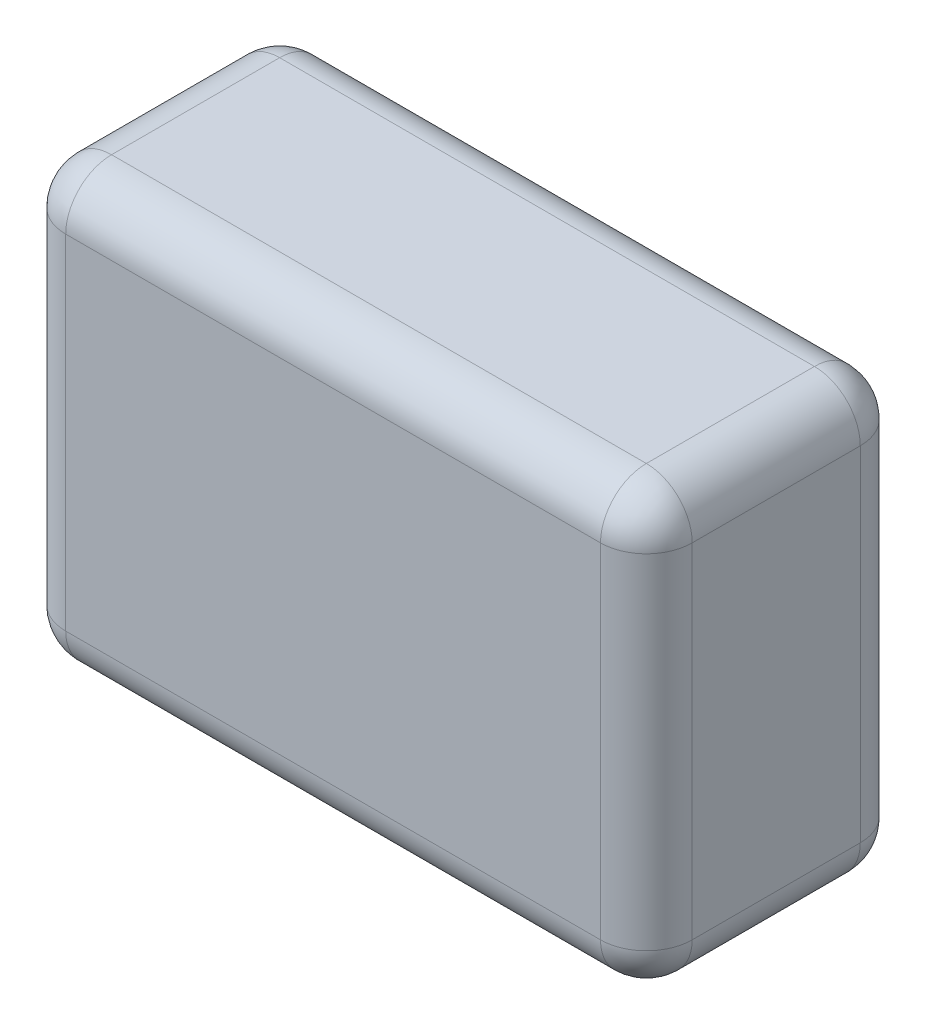
from build123d import *

# Parameters (mm, degrees)
SKETCH1_W           = 82
SKETCH1_H           = 34
BOSS_EXTRUDE1_DEPTH = 28.5
FILLET1_R           = 6


with BuildPart() as part:
    # Sketch1 → Boss-Extrude1 (new body, symmetric)
    with BuildSketch(Plane(origin=(0, 0, 0), x_dir=(1, 0, 0), z_dir=(0, 1, 0))):
        Rectangle(SKETCH1_W, SKETCH1_H)
    extrude(amount=BOSS_EXTRUDE1_DEPTH, both=True)

    # Fillet1
    fillet1_edges = [part.edges().sort_by_distance(p)[0] for p in [
        (41, 28.5, 0),
        (0, 28.5, -17),
        (-41, 28.5, 0),
        (0, -28.5, -17),
        (41, -28.5, 0),
        (0, -28.5, 17),
        (-41, -28.5, 0),
        (-41, 0, -17),
        (41, 0, -17),
        (41, 0, 17),
        (-41, 0, 17),
        (0, 28.5, 17),
    ]]
    fillet(fillet1_edges, radius=FILLET1_R)


solid = part.part
